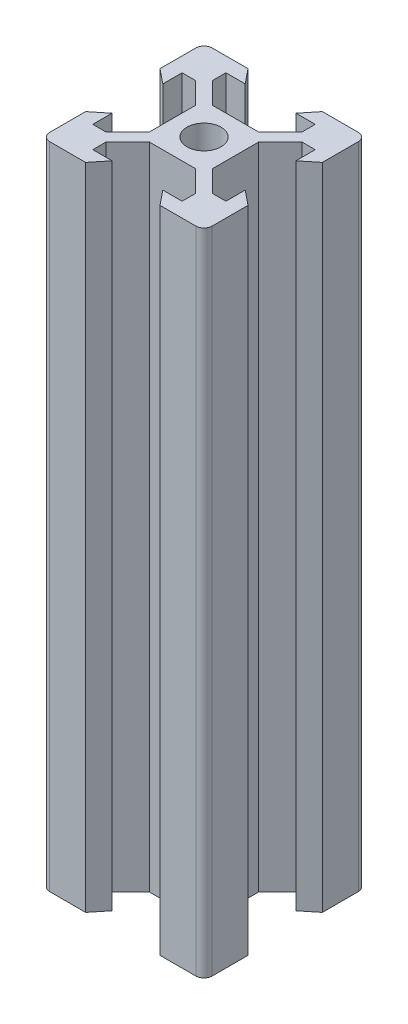
from build123d import *

# Parameters (mm, degrees)
SKETCH1_R           = 2.1
BOSS_EXTRUDE1_DEPTH = 80


with BuildPart() as part:
    # Sketch1 → Boss-Extrude1 (new body)
    with BuildSketch(Plane(origin=(0, 0, 0), x_dir=(1, 0, 0), z_dir=(0, 1, 0))):
        with BuildLine():
            Line((-5.5, 8.2), (-3.125, 8.2))
            Line((-3.125, 8.2), (-4.58, 10))
            Line((-4.58, 10), (-9, 10))
            ThreePointArc((-9, 10), (-9.707106781, 9.707106781), (-10, 9))
            Line((-10, 9), (-10, 4.58))
            Line((-10, 4.58), (-8.2, 3.125))
            Line((-8.2, 3.125), (-8.2, 5.5))
            Line((-8.2, 5.5), (-6.56, 5.5))
            Line((-6.56, 5.5), (-3.9, 2.84))
            Line((-3.9, 2.84), (-3.9, -2.84))
            Line((-3.9, -2.84), (-6.56, -5.5))
            Line((-6.56, -5.5), (-8.2, -5.5))
            Line((-8.2, -5.5), (-8.2, -3.125))
            Line((-8.2, -3.125), (-10, -4.58))
            Line((-10, -4.58), (-10, -9))
            ThreePointArc((-10, -9), (-9.707106781, -9.707106781), (-9, -10))
            Line((-9, -10), (-4.58, -10))
            Line((-4.58, -10), (-3.125, -8.2))
            Line((-3.125, -8.2), (-5.5, -8.2))
            Line((-5.5, -8.2), (-5.5, -6.56))
            Line((-5.5, -6.56), (-2.84, -3.9))
            Line((-2.84, -3.9), (2.84, -3.9))
            Line((2.84, -3.9), (5.5, -6.56))
            Line((5.5, -6.56), (5.5, -8.2))
            Line((5.5, -8.2), (3.125, -8.2))
            Line((3.125, -8.2), (4.58, -10))
            Line((4.58, -10), (9, -10))
            ThreePointArc((9, -10), (9.707106781, -9.707106781), (10, -9))
            Line((10, -9), (10, -4.58))
            Line((10, -4.58), (8.2, -3.125))
            Line((8.2, -3.125), (8.2, -5.5))
            Line((8.2, -5.5), (6.56, -5.5))
            Line((6.56, -5.5), (3.9, -2.84))
            Line((3.9, -2.84), (3.9, 2.84))
            Line((3.9, 2.84), (6.56, 5.5))
            Line((6.56, 5.5), (8.2, 5.5))
            Line((8.2, 5.5), (8.2, 3.125))
            Line((8.2, 3.125), (10, 4.58))
            Line((10, 4.58), (10, 9))
            ThreePointArc((10, 9), (9.707106781, 9.707106781), (9, 10))
            Line((9, 10), (4.58, 10))
            Line((4.58, 10), (3.125, 8.2))
            Line((3.125, 8.2), (5.5, 8.2))
            Line((5.5, 8.2), (5.5, 6.56))
            Line((5.5, 6.56), (2.84, 3.9))
            Line((2.84, 3.9), (-2.84, 3.9))
            Line((-2.84, 3.9), (-5.5, 6.56))
            Line((-5.5, 6.56), (-5.5, 8.2))
        make_face()
        Circle(SKETCH1_R, mode=Mode.SUBTRACT)
    extrude(amount=BOSS_EXTRUDE1_DEPTH)


solid = part.part
